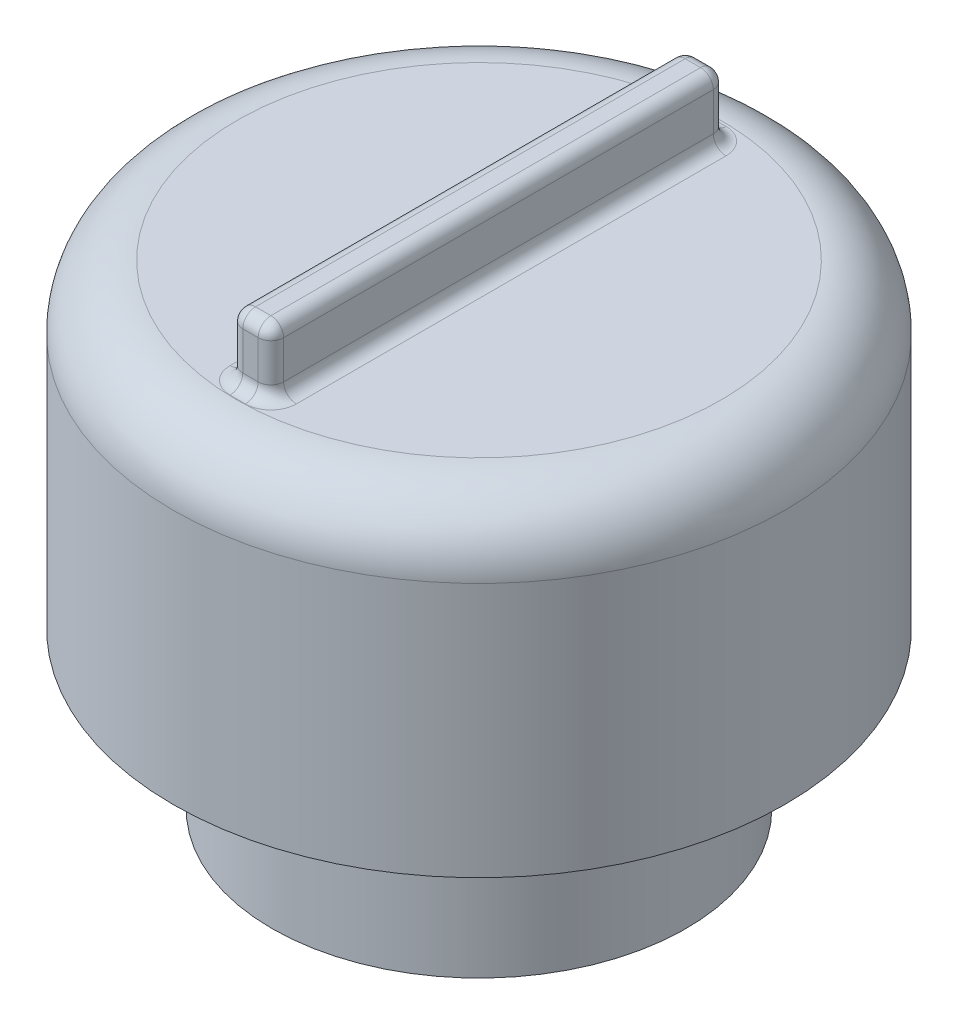
from build123d import *

# Parameters (mm, degrees)
SKETCH1_R           = 3.25
BOSS_EXTRUDE1_DEPTH = 2.46
SKETCH2_R           = 1.75
CUT_EXTRUDE1_DEPTH  = 2.5
SKETCH6_R           = 4.8
BOSS_EXTRUDE2_DEPTH = 5
SKETCH11_W          = 0.64110577
SKETCH11_H          = 7.14375
BOSS_EXTRUDE4_DEPTH = 1
FILLET1_R           = 0.2
FILLET2_R           = 1


with BuildPart() as part:
    # Sketch1 → Boss-Extrude1 (new body)
    with BuildSketch(Plane(origin=(0, 0, 0), x_dir=(1, 0, 0), z_dir=(0, 1, 0))):
        with Locations(Location((0, 0, 0), (0, 0, 270))):
            Circle(SKETCH1_R)
    extrude(amount=BOSS_EXTRUDE1_DEPTH)

    # Sketch2 → Cut-Extrude1 (cut)
    with BuildSketch(Plane.XZ):
        with Locations(Location((0, 0, 0), (0, 0, 270))):
            Circle(SKETCH2_R)
    extrude(amount=-CUT_EXTRUDE1_DEPTH, mode=Mode.SUBTRACT)

    # Sketch6 → Boss-Extrude2 (add)
    with BuildSketch(Plane(origin=(0, 2.46, 0), x_dir=(1, 0, 0), z_dir=(0, 1, 0))):
        with Locations(Location((0, 0, 0), (0, 0, 270))):
            Circle(SKETCH6_R)
    extrude(amount=BOSS_EXTRUDE2_DEPTH)

    # Sketch11 → Boss-Extrude4 (add)
    with BuildSketch(Plane(origin=(0, 7.46, 0), x_dir=(1, 0, 0), z_dir=(0, 1, 0))):
        with Locations((0, -0.015014366)):
            Rectangle(SKETCH11_W, SKETCH11_H)
    extrude(amount=BOSS_EXTRUDE4_DEPTH)

    # Fillet1
    fillet1_edges = [part.edges().sort_by_distance(p)[0] for p in [
        (-0.320552885, 8.46, 0.015014366),
        (-0.320552885, 7.96, -3.556860634),
        (0, 8.46, 3.586889366),
        (-0.320552885, 7.96, 3.586889366),
        (0.320552885, 8.46, 0.015014366),
        (0.320552885, 7.96, 3.586889366),
        (0, 8.46, -3.556860634),
        (0.320552885, 7.96, -3.556860634),
        (-0.320552885, 7.46, 0.015014366),
        (0, 7.46, -3.556860634),
        (0.320552885, 7.46, 0.015014366),
        (0, 7.46, 3.586889366),
    ]]
    fillet(fillet1_edges, radius=FILLET1_R)

    # Fillet2
    fillet2_edges = [part.edges().sort_by_distance(p)[0] for p in [
        (0, 7.46, -4.8),
    ]]
    fillet(fillet2_edges, radius=FILLET2_R)


solid = part.part
